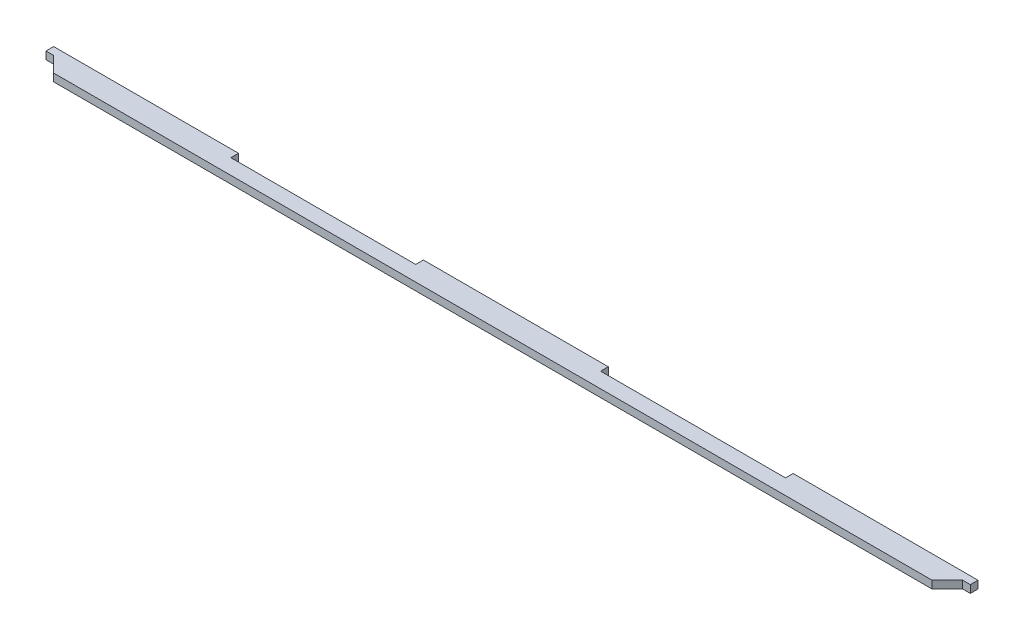
from build123d import *

# Parameters (mm, degrees)
BOSS_EXTRUDE1_DEPTH = 3


with BuildPart() as part:
    # Sketch1 → Boss-Extrude1 (new body)
    with BuildSketch(Plane(origin=(0, 0, 0), x_dir=(1, 0, 0), z_dir=(0, 1, 0))):
        Polygon((-181.15, 4.078871625), (-108.69, 4.078871625), (-108.69, 1.078871625), (-36.23, 1.078871625), (-36.23, 4.078871625), (36.23, 4.078871625), (36.23, 1.078871625), (108.69, 1.078871625), (108.69, 4.078871625), (181.15, 4.078871625), (181.15, 1.078871625), (178.15, 1.078871625), (172.15, -4.921128375), (-172.15, -4.921128375), (-178.15, 1.078871625), (-181.15, 1.078871625), align=None)
    extrude(amount=BOSS_EXTRUDE1_DEPTH)


solid = part.part
